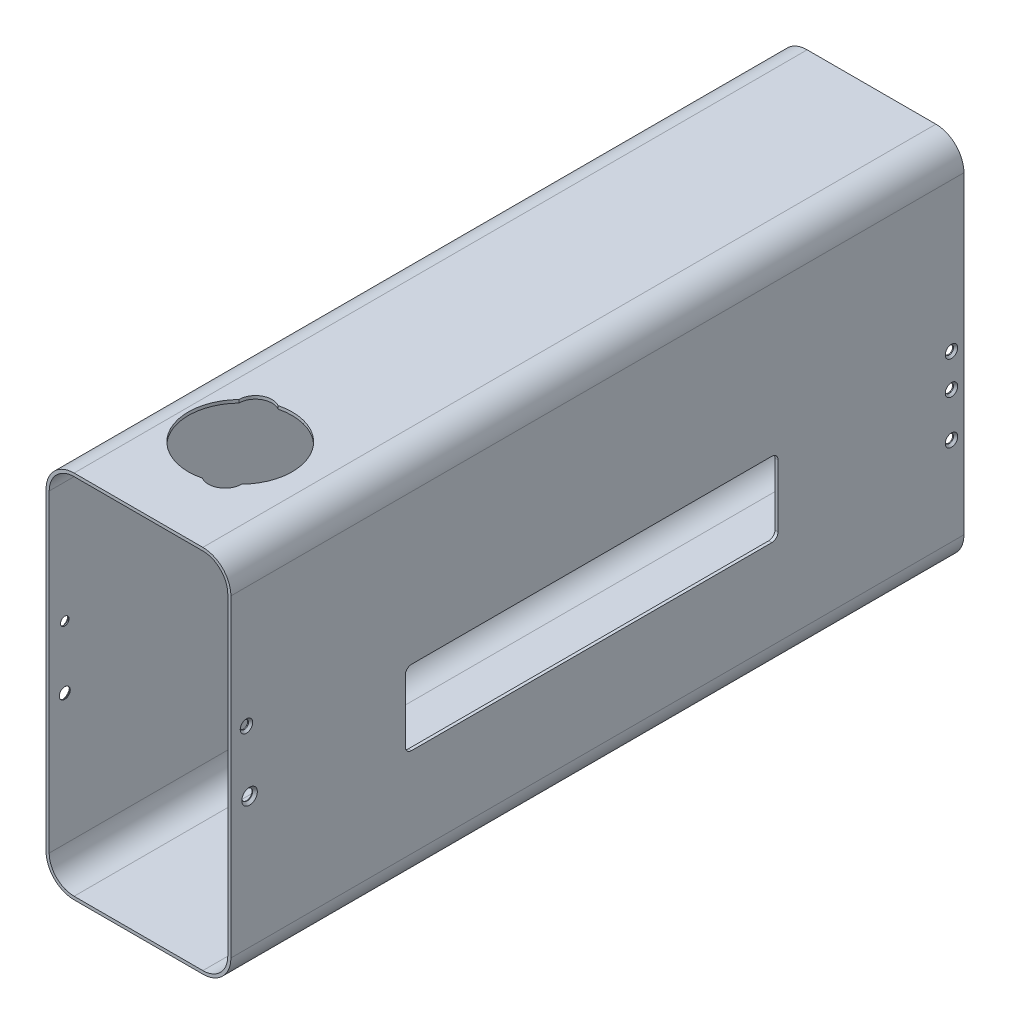
from build123d import *

# Parameters (mm, degrees)
EXTRUDE_1_DEPTH             = 353
CUT_EXTRUDE_1_REACH         = 91
HOLE_WIZARD_M3_1_AT_2_COUNT = 2
HOLE_WIZARD_M3_1_AT_2_PITCH = 339.768303407
HOLE_WIZARD_M3_1_AT_3_COUNT = 2
HOLE_WIZARD_M3_1_AT_3_PITCH = 340.779254063
HOLE_WIZARD_M3_1_AT_4_COUNT = 2
HOLE_WIZARD_M3_1_AT_4_PITCH = 343.235342003
HOLE_WIZARD_3_2_AT_2_COUNT  = 2
HOLE_WIZARD_3_2_AT_2_PITCH  = 339.809505459
HOLE_WIZARD_3_2_AT_3_COUNT  = 2
HOLE_WIZARD_3_2_AT_3_PITCH  = 343.235342003
HOLE_WIZARD_3_2_AT_4_COUNT  = 2
HOLE_WIZARD_3_2_AT_4_PITCH  = 341.350992382
CUT_EXTRUDE_3_REACH         = 180


with BuildPart() as part:
    # Эскиз1 → Бобышка-Вытянуть1 (new body)
    with BuildSketch(Plane.XY):
        with BuildLine():
            Line((-44.5, -75.5), (-44.5, 75.5))
            ThreePointArc((-44.5, 75.5), (-40.545941546, 85.045941546), (-31, 89))
            Line((-31, 89), (31, 89))
            ThreePointArc((31, 89), (40.545941546, 85.045941546), (44.5, 75.5))
            Line((44.5, 75.5), (44.5, -75.5))
            ThreePointArc((44.5, -75.5), (40.545941546, -85.045941546), (31, -89))
            Line((31, -89), (-31, -89))
            ThreePointArc((-31, -89), (-40.545941546, -85.045941546), (-44.5, -75.5))
        make_face()
        with BuildLine():
            Line((-31, -87.5), (31, -87.5))
            ThreePointArc((31, -87.5), (39.485281374, -83.985281374), (43, -75.5))
            Line((43, -75.5), (43, 75.5))
            ThreePointArc((43, 75.5), (39.485281374, 83.985281374), (31, 87.5))
            Line((31, 87.5), (-31, 87.5))
            ThreePointArc((-31, 87.5), (-39.485281374, 83.985281374), (-43, 75.5))
            Line((-43, 75.5), (-43, -75.5))
            ThreePointArc((-43, -75.5), (-39.485281374, -83.985281374), (-31, -87.5))
        make_face(mode=Mode.SUBTRACT)
    extrude(amount=EXTRUDE_1_DEPTH)

    # Эскиз2 → Вырез-Вытянуть1 (cut, up to next)
    with BuildSketch(Plane(origin=(44.5, 0, 0), x_dir=(0, 0, -1), z_dir=(1, 0, 0)), mode=Mode.PRIVATE) as cut_extrude_1_sk1:
        with BuildLine():
            Line((-266, 3.5), (-92.5, 3.5))
            ThreePointArc((-92.5, 3.5), (-90.378679656, 2.621320344), (-89.5, 0.5))
            Line((-89.5, 0.5), (-89.5, -29.5))
            ThreePointArc((-89.5, -29.5), (-90.378679656, -31.621320344), (-92.5, -32.5))
            Line((-92.5, -32.5), (-266, -32.5))
            ThreePointArc((-266, -32.5), (-268.121320344, -31.621320344), (-269, -29.5))
            Line((-269, -29.5), (-269, 0.5))
            ThreePointArc((-269, 0.5), (-268.121320344, 2.621320344), (-266, 3.5))
        make_face()
    cut_extrude_1_tool1 = extrude(cut_extrude_1_sk1.sketch, amount=-CUT_EXTRUDE_1_REACH, mode=Mode.PRIVATE) & part.part
    add(cut_extrude_1_tool1.solids().sort_by_distance((44.5, -14.5, 179.25))[0], mode=Mode.SUBTRACT)

    # Эскиз4 → M3_впотай_1 (revolve, cut)
    with BuildSketch(Plane(origin=(44.5, 17.5, 345.5), x_dir=(0, 0, -1), z_dir=(0, 1, 0))):
        Polygon((0, 0), (0, 1.5), (2.05, 1.5), (2, 1.45), (2, 1), (3, 0), align=None)
    hole_wizard_m3_1 = revolve(axis=Axis((50.85, 17.5, 345.5), (-1, 0, 0)), mode=Mode.SUBTRACT)

    # M3_впотай_1 at 2: M3_впотай_1 ×2
    with Locations(*[Vector(0, -0.039732959, -0.999210334) * (i * HOLE_WIZARD_M3_1_AT_2_PITCH) for i in range(1, HOLE_WIZARD_M3_1_AT_2_COUNT)]):
        add(hole_wizard_m3_1, mode=Mode.SUBTRACT)

    # M3_впотай_1 at 3: M3_впотай_1 ×2
    with Locations(*[Vector(0, -0.086566303, -0.996246092) * (i * HOLE_WIZARD_M3_1_AT_3_PITCH) for i in range(1, HOLE_WIZARD_M3_1_AT_3_COUNT)]):
        add(hole_wizard_m3_1, mode=Mode.SUBTRACT)

    # M3_впотай_1 at 4: M3_впотай_1 ×2
    with Locations(*[Vector(0, -0.147129371, -0.989117257) * (i * HOLE_WIZARD_M3_1_AT_4_PITCH) for i in range(1, HOLE_WIZARD_M3_1_AT_4_COUNT)]):
        add(hole_wizard_m3_1, mode=Mode.SUBTRACT)

    # Эскиз6 → М3_впотай_2 (revolve, cut)
    with BuildSketch(Plane(origin=(-44.5, 17.5, 345.5), x_dir=(0, 0, 1), z_dir=(0, 1, 0))):
        Polygon((0, 0), (0, 1.5), (2.05, 1.5), (2, 1.45), (2, 1), (3, 0), align=None)
    hole_wizard_3_2 = revolve(axis=Axis((-50.85, 17.5, 345.5), (1, 0, 0)), mode=Mode.SUBTRACT)

    # М3_впотай_2 at 2: М3_впотай_2 ×2
    with Locations(*[Vector(0, -0.042670966, -0.99908918) * (i * HOLE_WIZARD_3_2_AT_2_PITCH) for i in range(1, HOLE_WIZARD_3_2_AT_2_COUNT)]):
        add(hole_wizard_3_2, mode=Mode.SUBTRACT)

    # М3_впотай_2 at 3: М3_впотай_2 ×2
    with Locations(*[Vector(0, -0.147129371, -0.989117257) * (i * HOLE_WIZARD_3_2_AT_3_PITCH) for i in range(1, HOLE_WIZARD_3_2_AT_3_COUNT)]):
        add(hole_wizard_3_2, mode=Mode.SUBTRACT)

    # М3_впотай_2 at 4: М3_впотай_2 ×2
    with Locations(*[Vector(0, -0.103998526, -0.994577451) * (i * HOLE_WIZARD_3_2_AT_4_PITCH) for i in range(1, HOLE_WIZARD_3_2_AT_4_COUNT)]):
        add(hole_wizard_3_2, mode=Mode.SUBTRACT)

    # Эскиз8 → Вырез-Вытянуть3 (cut, up to next)
    with BuildSketch(Plane(origin=(0, 89, 0), x_dir=(1, 0, 0), z_dir=(0, 1, 0)), mode=Mode.PRIVATE) as cut_extrude_3_sk1:
        with BuildLine():
            ThreePointArc((-21.999947808, -282.650594278), (-25.650635095, -312.5), (2.025052192, -324.263114929))
            ThreePointArc((2.025052192, -324.263114929), (10, -324.248711306), (13.999947808, -317.349405722))
            ThreePointArc((13.999947808, -317.349405722), (17.650635095, -287.5), (-10.025052192, -275.736885071))
            ThreePointArc((-10.025052192, -275.736885071), (-18, -275.751288694), (-21.999947808, -282.650594278))
        make_face()
    cut_extrude_3_tool1 = extrude(cut_extrude_3_sk1.sketch, amount=-CUT_EXTRUDE_3_REACH, mode=Mode.PRIVATE) & part.part
    add(cut_extrude_3_tool1.solids().sort_by_distance((-4, 89, 300))[0], mode=Mode.SUBTRACT)

    # Эскиз9 → Зенковка для винта с потайной головкой M41 (revolve, cut)
    with BuildSketch(Plane(origin=(44.5, -12.5, 344), x_dir=(0, 0, -1), z_dir=(0, 1, 0))):
        Polygon((0, 0), (0, 1.5), (2.65, 1.5), (2.6, 1.45), (2.6, 1.15), (3.75, 0), align=None)
    revolve(axis=Axis((50.85, -12.5, 344), (-1, 0, 0)), mode=Mode.SUBTRACT)

    # Эскиз13 → Зенковка для винта с потайной головкой M43 (revolve, cut)
    with BuildSketch(Plane(origin=(-44.5, -12.5, 345.5), x_dir=(0, 0, 1), z_dir=(0, 1, 0))):
        Polygon((0, 0), (0, 1.5), (2.65, 1.5), (2.6, 1.45), (2.6, 1.15), (3.75, 0), align=None)
    revolve(axis=Axis((-50.85, -12.5, 345.5), (1, 0, 0)), mode=Mode.SUBTRACT)


solid = part.part
